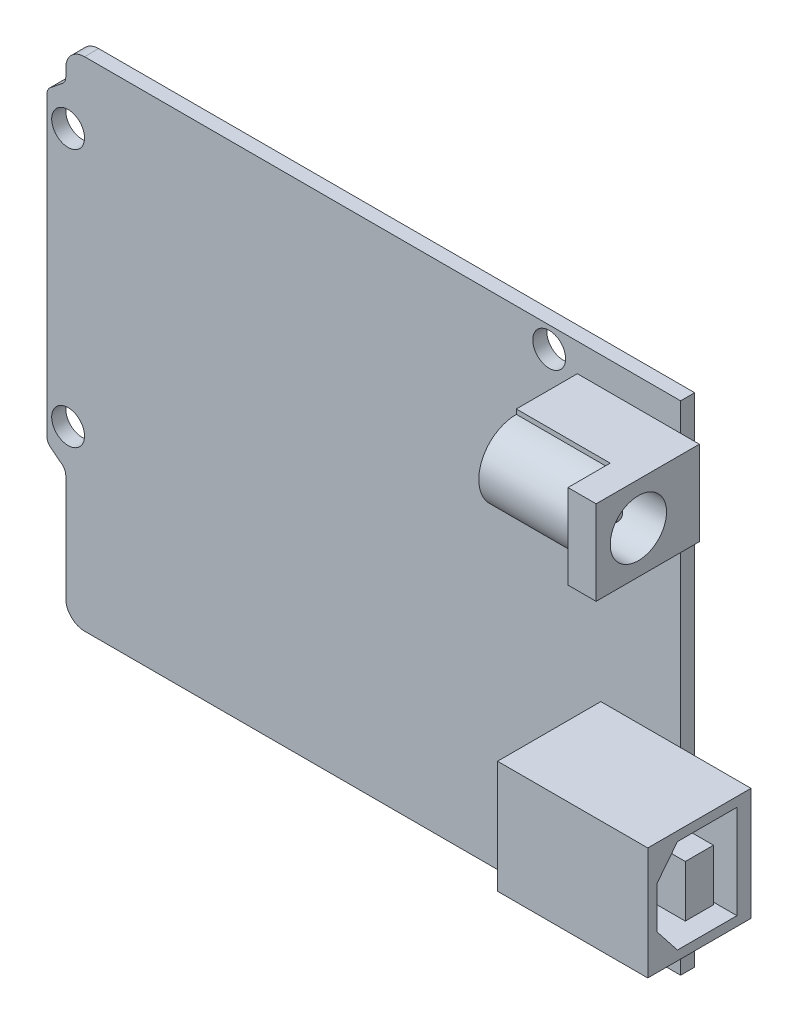
from build123d import *

# Parameters (mm, degrees)
SKETCH1_W           = 67.5
SKETCH1_H           = 53
SKETCH1_R           = 1.75
SKETCH1_W_2         = 7.5
BOSS_EXTRUDE1_DEPTH = 1.5
CUT_EXTRUDE1_DEPTH  = 2
FILLET1_R           = 1
FILLET2_R           = 2
SKETCH3_W           = 7.5
SKETCH3_H           = 9
CUT_EXTRUDE2_DEPTH  = 2
BOSS_EXTRUDE2_DEPTH = 11
SKETCH5_W           = 7.5
SKETCH5_H           = 12
CUT_EXTRUDE3_DEPTH  = 1.5
SKETCH6_W           = 3
SKETCH6_H           = 5.5
CUT_EXTRUDE4_DEPTH  = 12
BOSS_EXTRUDE3_DEPTH = 11
SKETCH8_W           = 2
SKETCH8_H           = 9
CUT_EXTRUDE5_DEPTH  = 1.5
SKETCH9_R           = 3
SKETCH9_R_2         = 0.75
CUT_EXTRUDE6_DEPTH  = 9
SKETCH10_R          = 0.75
CUT_EXTRUDE7_DEPTH  = 2
FILLET3_R           = 0.75
CUT_EXTRUDE8_DEPTH  = 10


with BuildPart() as part:
    # Sketch1 → Boss-Extrude1 (new body)
    with BuildSketch(Plane.XY):
        with Locations((-3.75, 0)):
            Rectangle(SKETCH1_W, SKETCH1_H)
        with Locations((-35.25, -8.5)):
            Circle(SKETCH1_R, mode=Mode.SUBTRACT)
        with Locations((16, -24.25)):
            Circle(SKETCH1_R, mode=Mode.SUBTRACT)
        with Locations((-35.25, 19)):
            Circle(SKETCH1_R, mode=Mode.SUBTRACT)
        with Locations((16, 24.25)):
            Circle(SKETCH1_R, mode=Mode.SUBTRACT)
        with Locations((33.75, 0)):
            Rectangle(SKETCH1_W_2, SKETCH1_H)
    extrude(amount=BOSS_EXTRUDE1_DEPTH)

    # Sketch2 → Cut-Extrude1 (cut)
    with BuildSketch(Plane.XY.offset(1.5)):
        Polygon((-37.5, 26.5), (-37.5, 21.544210715), (-35.5, 23.131873366), (-35.5, 26.5), align=None)
        Polygon((-37.5, -11.044210715), (-37.5, -26.5), (-35.5, -26.5), (-35.5, -16), (-35.5, -12.631873366), align=None)
    extrude(amount=-CUT_EXTRUDE1_DEPTH, mode=Mode.SUBTRACT)

    # Fillet1
    fillet1_edges = [part.edges().sort_by_distance(p)[0] for p in [
        (-35.5, 23.131873366, 0.75),
        (-37.5, 21.544210715, 0.75),
        (-35.5, -12.631873366, 0.75),
        (-37.5, -11.044210715, 0.75),
    ]]
    fillet(fillet1_edges, radius=FILLET1_R)

    # Fillet2
    fillet2_edges = [part.edges().sort_by_distance(p)[0] for p in [
        (-35.5, 26.5, 0.75),
        (-35.5, -26.5, 0.75),
    ]]
    fillet(fillet2_edges, radius=FILLET2_R)

    # Sketch3 → Cut-Extrude2 (cut)
    with BuildSketch(Plane.XY.offset(1.5)):
        Polygon((30, -5.5), (37.5, -5.5), (37.5, 26.5), (30, 26.5), (30, 23.5), (32, 23.5), (32, 14.5), (30, 14.5), align=None)
        with Locations((33.75, -22)):
            Rectangle(SKETCH3_W, SKETCH3_H)
    extrude(amount=-CUT_EXTRUDE2_DEPTH, mode=Mode.SUBTRACT)

    # Sketch4 → Boss-Extrude2 (add)
    with BuildSketch(Plane.XY.offset(1.5)):
        Polygon((37.5, -17.5), (30, -17.5), (21.5, -17.5), (21.5, -5.5), (30, -5.5), (37.5, -5.5), align=None)
    extrude(amount=BOSS_EXTRUDE2_DEPTH)

    # Sketch5 → Cut-Extrude3 (cut)
    with BuildSketch(Plane(origin=(0, 0, 0), x_dir=(-1, 0, 0), z_dir=(0, 0, -1))):
        with Locations((-33.75, -11.5)):
            Rectangle(SKETCH5_W, SKETCH5_H)
    extrude(amount=-CUT_EXTRUDE3_DEPTH, mode=Mode.SUBTRACT)

    # Sketch6 → Cut-Extrude4 (cut)
    with BuildSketch(Plane(origin=(37.5, 0, 0), x_dir=(0, 0, -1), z_dir=(1, 0, 0))):
        Polygon((-3, -16.5), (-3, -6.5), (-9.334936491, -6.5), (-11.5, -9.25), (-11.5, -13.75), (-9.334936491, -16.5), align=None)
        with Locations((-7, -11.5)):
            Rectangle(SKETCH6_W, SKETCH6_H, mode=Mode.SUBTRACT)
    extrude(amount=-CUT_EXTRUDE4_DEPTH, mode=Mode.SUBTRACT)

    # Sketch7 → Boss-Extrude3 (add)
    with BuildSketch(Plane.XY.offset(1.5)):
        Polygon((32, 14.5), (30, 14.5), (19, 14.5), (19, 23.5), (30, 23.5), (32, 23.5), align=None)
    extrude(amount=BOSS_EXTRUDE3_DEPTH)

    # Sketch8 → Cut-Extrude5 (cut)
    with BuildSketch(Plane(origin=(0, 0, 0), x_dir=(-1, 0, 0), z_dir=(0, 0, -1))):
        with Locations((-31, 19)):
            Rectangle(SKETCH8_W, SKETCH8_H)
    extrude(amount=-CUT_EXTRUDE5_DEPTH, mode=Mode.SUBTRACT)

    # Sketch9 → Cut-Extrude6 (cut)
    with BuildSketch(Plane(origin=(32, 0, 0), x_dir=(0, 0, -1), z_dir=(1, 0, 0))):
        with Locations((-8, 19)):
            Circle(SKETCH9_R)
        with Locations((-8, 19)):
            Circle(SKETCH9_R_2, mode=Mode.SUBTRACT)
    extrude(amount=-CUT_EXTRUDE6_DEPTH, mode=Mode.SUBTRACT)

    # Sketch10 → Cut-Extrude7 (cut)
    with BuildSketch(Plane(origin=(32, 0, 0), x_dir=(0, 0, -1), z_dir=(1, 0, 0))):
        with Locations((-8, 19)):
            Circle(SKETCH10_R)
    extrude(amount=-CUT_EXTRUDE7_DEPTH, mode=Mode.SUBTRACT)

    # Fillet3
    fillet3_edges = [part.edges().sort_by_distance(p)[0] for p in [
        (30, 19, 8.75),
    ]]
    fillet(fillet3_edges, radius=FILLET3_R)

    # Sketch11 → Cut-Extrude8 (cut)
    with BuildSketch(Plane.ZY.offset(-19)):
        with BuildLine():
            Line((8, 14.5), (12.5, 14.5))
            Line((12.5, 14.5), (12.5, 23.5))
            Line((12.5, 23.5), (8, 23.5))
            Line((8, 23.5), (8, 23))
            ThreePointArc((8, 23), (12, 19), (8, 15))
            Line((8, 15), (8, 14.5))
        make_face()
    extrude(amount=-CUT_EXTRUDE8_DEPTH, mode=Mode.SUBTRACT)


solid = part.part
